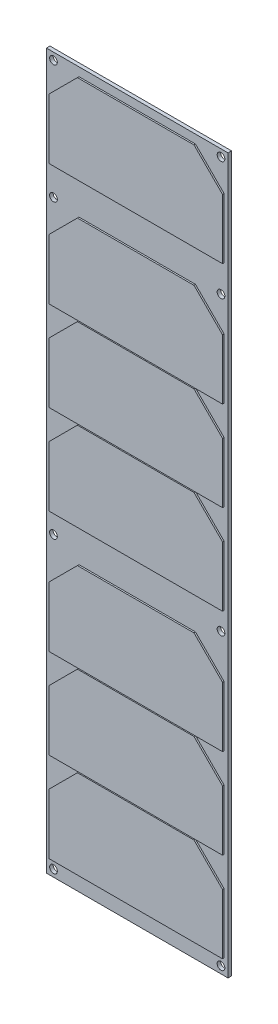
from build123d import *

# Parameters (mm, degrees)
SKETCH1_W           = 82.6
SKETCH1_H           = 325
SKETCH1_R           = 1.75
BOSS_EXTRUDE4_DEPTH = 1.6
BOSS_EXTRUDE5_DEPTH = 2.3


with BuildPart() as part:
    # Sketch1 → Boss-Extrude4 (new body)
    with BuildSketch(Plane.XY):
        with Locations((-52.667971546, -86.514453125)):
            Rectangle(SKETCH1_W, SKETCH1_H)
        with Locations((-90.767971546, 72.785546875)):
            Circle(SKETCH1_R, mode=Mode.SUBTRACT)
        with Locations((-14.567971546, 72.785546875)):
            Circle(SKETCH1_R, mode=Mode.SUBTRACT)
        with Locations((-14.567971546, -245.814453125)):
            Circle(SKETCH1_R, mode=Mode.SUBTRACT)
        with Locations((-90.767971546, -245.814453125)):
            Circle(SKETCH1_R, mode=Mode.SUBTRACT)
        with Locations((-90.767971546, -114.014453125)):
            Circle(SKETCH1_R, mode=Mode.SUBTRACT)
        with Locations((-14.567971546, -114.014453125)):
            Circle(SKETCH1_R, mode=Mode.SUBTRACT)
        with Locations((-90.767971546, 18.785546875)):
            Circle(SKETCH1_R, mode=Mode.SUBTRACT)
        with Locations((-14.567971546, 18.785546875)):
            Circle(SKETCH1_R, mode=Mode.SUBTRACT)
        Polygon((-92.167971546, -214.714453125), (-79.167971546, -201.714453125), (-26.167971546, -201.714453125), (-13.167971546, -214.714453125), (-13.167971546, -242.014453125), (-92.167971546, -242.014453125), align=None, mode=Mode.SUBTRACT)
        Polygon((-92.167971546, -173.914453125), (-79.167971546, -160.914453125), (-26.167971546, -160.914453125), (-13.167971546, -173.914453125), (-13.167971546, -201.214453125), (-92.167971546, -201.214453125), align=None, mode=Mode.SUBTRACT)
        Polygon((-92.167971546, -37.014453125), (-79.167971546, -24.014453125), (-26.167971546, -24.014453125), (-13.167971546, -37.014453125), (-13.167971546, -64.314453125), (-92.167971546, -64.314453125), align=None, mode=Mode.SUBTRACT)
        Polygon((-92.167971546, -133.114453125), (-79.167971546, -120.114453125), (-26.167971546, -120.114453125), (-13.167971546, -133.114453125), (-13.167971546, -160.414453125), (-92.167971546, -160.414453125), align=None, mode=Mode.SUBTRACT)
        Polygon((-92.167971546, -77.814453125), (-79.167971546, -64.814453125), (-26.167971546, -64.814453125), (-13.167971546, -77.814453125), (-13.167971546, -105.114453125), (-92.167971546, -105.114453125), align=None, mode=Mode.SUBTRACT)
        Polygon((-92.167971546, 3.785546875), (-79.167971546, 16.785546875), (-26.167971546, 16.785546875), (-13.167971546, 3.785546875), (-13.167971546, -23.514453125), (-92.167971546, -23.514453125), align=None, mode=Mode.SUBTRACT)
        Polygon((-92.167971546, 59.085546875), (-79.167970879, 72.085546875), (-26.167970879, 72.085546875), (-13.167971546, 59.085546875), (-13.167971546, 31.785546875), (-92.167971546, 31.785546875), align=None, mode=Mode.SUBTRACT)
    extrude(amount=BOSS_EXTRUDE4_DEPTH)

    # Sketch1_8 → Boss-Extrude5 (add)
    with BuildSketch(Plane.XY):
        Polygon((-79.167971546, -201.714453125), (-92.167971546, -214.714453125), (-92.167971546, -242.014453125), (-13.167971546, -242.014453125), (-13.167971546, -214.714453125), (-26.167971546, -201.714453125), align=None)
        Polygon((-79.167971546, -160.914453125), (-92.167971546, -173.914453125), (-92.167971546, -201.214453125), (-13.167971546, -201.214453125), (-13.167971546, -173.914453125), (-26.167971546, -160.914453125), align=None)
        Polygon((-79.167971546, -24.014453125), (-92.167971546, -37.014453125), (-92.167971546, -64.314453125), (-13.167971546, -64.314453125), (-13.167971546, -37.014453125), (-26.167971546, -24.014453125), align=None)
        Polygon((-79.167971546, -120.114453125), (-92.167971546, -133.114453125), (-92.167971546, -160.414453125), (-13.167971546, -160.414453125), (-13.167971546, -133.114453125), (-26.167971546, -120.114453125), align=None)
        Polygon((-79.167971546, -64.814453125), (-92.167971546, -77.814453125), (-92.167971546, -105.114453125), (-13.167971546, -105.114453125), (-13.167971546, -77.814453125), (-26.167971546, -64.814453125), align=None)
        Polygon((-79.167971546, 16.785546875), (-92.167971546, 3.785546875), (-92.167971546, -23.514453125), (-13.167971546, -23.514453125), (-13.167971546, 3.785546875), (-26.167971546, 16.785546875), align=None)
        Polygon((-79.167970879, 72.085546875), (-92.167971546, 59.085546875), (-92.167971546, 31.785546875), (-13.167971546, 31.785546875), (-13.167971546, 59.085546875), (-26.167970879, 72.085546875), align=None)
    extrude(amount=BOSS_EXTRUDE5_DEPTH)


solid = part.part
